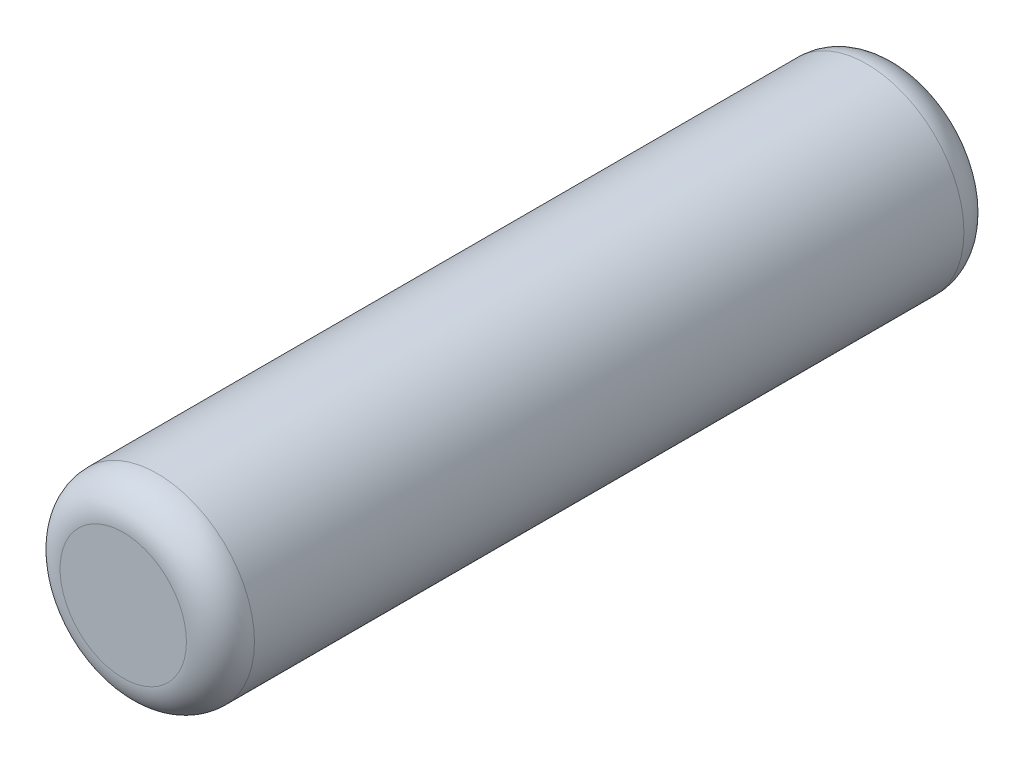
from build123d import *

# Parameters (mm, degrees)
SKETCH1_R           = 1
BOSS_EXTRUDE1_DEPTH = 4
FILLET1_R           = 0.35


with BuildPart() as part:
    # Sketch1 → Boss-Extrude1 (new body, symmetric)
    with BuildSketch(Plane.XY):
        Circle(SKETCH1_R)
    extrude(amount=BOSS_EXTRUDE1_DEPTH, both=True)

    # Fillet1
    fillet1_edges = [part.edges().sort_by_distance(p)[0] for p in [
        (-1, 0, -4),
        (-1, 0, 4),
    ]]
    fillet(fillet1_edges, radius=FILLET1_R)


solid = part.part
